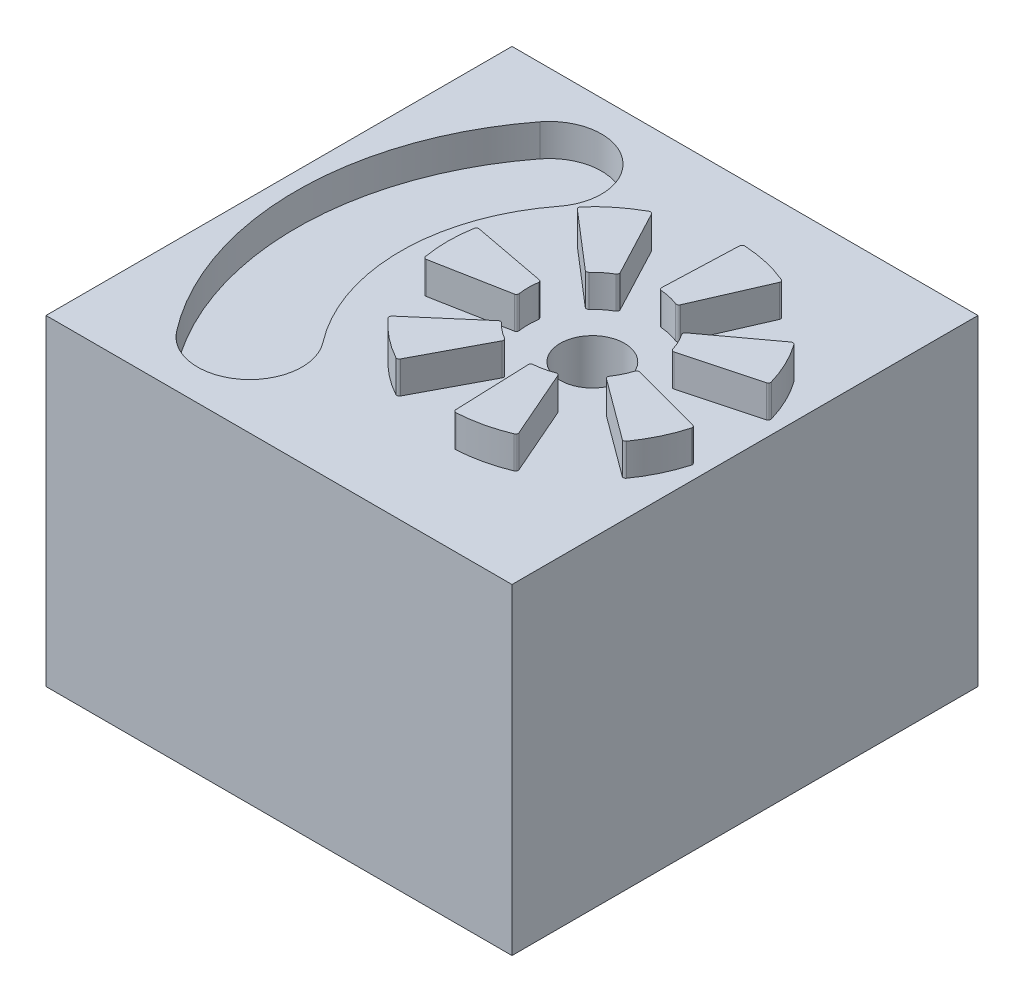
from build123d import *

# Parameters (mm, degrees)
SKETCH1_W           = 92.075
SKETCH1_H           = 92.075
BOSS_EXTRUDE1_DEPTH = 63.5
CUT_EXTRUDE1_DEPTH  = 6.35
BOSS_EXTRUDE2_DEPTH = 6.35
SKETCH5_R           = 6.35
CUT_EXTRUDE2_DEPTH  = 19.05


with BuildPart() as part:
    # Sketch1 → Boss-Extrude1 (new body)
    with BuildSketch(Plane(origin=(0, 0, 0), x_dir=(1, 0, 0), z_dir=(0, 1, 0))):
        Rectangle(SKETCH1_W, SKETCH1_H)
    extrude(amount=-BOSS_EXTRUDE1_DEPTH)

    # Sketch3 → Cut-Extrude1 (cut)
    with BuildSketch(Plane(origin=(0, 0, 0), x_dir=(1, 0, 0), z_dir=(0, 1, 0))):
        with BuildLine():
            ThreePointArc((-14.063201547, 23.287775446), (-15.921775446, 37.752798453), (-30.386798453, 35.894224554))
            ThreePointArc((-30.386798453, 35.894224554), (-42.633573767, 0), (-30.386798453, -35.894224554))
            ThreePointArc((-30.386798453, -35.894224554), (-15.921775446, -37.752798453), (-14.063201547, -23.287775446))
            ThreePointArc((-14.063201547, -23.287775446), (-22.008773767, 0), (-14.063201547, 23.287775446))
        make_face()
    extrude(amount=-CUT_EXTRUDE1_DEPTH, mode=Mode.SUBTRACT)

    # Sketch4 → Boss-Extrude2 (add)
    with BuildSketch(Plane(origin=(0, 0, 0), x_dir=(1, 0, 0), z_dir=(0, 1, 0))):
        with BuildLine():
            Line((42.981199166, 7.263084177), (28.623508469, 3.415952549))
            ThreePointArc((28.623508469, 3.415952549), (28.246537351, 3.461897832), (28.006758071, 3.756387374))
            ThreePointArc((28.006758071, 3.756387374), (27.317235926, 5.510466133), (26.375711245, 7.143182998))
            ThreePointArc((26.375711245, 7.143182998), (26.294960734, 7.5142592), (26.49406885, 7.837638468))
            Line((26.49406885, 7.837638468), (38.453531121, 16.664583926))
            ThreePointArc((38.453531121, 16.664583926), (38.835445953, 16.757478046), (39.169323269, 16.550079409))
            ThreePointArc((39.169323269, 16.550079409), (41.620030834, 12.3985488), (43.337949301, 7.894114306))
            ThreePointArc((43.337949301, 7.894114306), (43.291940716, 7.503766427), (42.981199166, 7.263084177))
        make_face()
        with BuildLine():
            Line((27.096930878, 25.720938792), (21.152865774, 12.096996853))
            ThreePointArc((21.152865774, 12.096996853), (20.881906657, 11.830915381), (20.502165527, 11.827059617))
            ThreePointArc((20.502165527, 11.827059617), (18.700861504, 12.381619715), (16.837321021, 12.663488392))
            ThreePointArc((16.837321021, 12.663488392), (16.496854843, 12.831717328), (16.368168631, 13.189009997))
            Line((16.368168631, 13.189009997), (16.923587539, 28.042804588))
            ThreePointArc((16.923587539, 28.042804588), (17.089079994, 28.399316164), (17.45939988, 28.531041026))
            ThreePointArc((17.45939988, 28.531041026), (22.233188385, 27.858644358), (26.826001728, 26.39329813))
            ThreePointArc((26.826001728, 26.39329813), (27.102502105, 26.113949248), (27.096930878, 25.720938792))
        make_face()
        with BuildLine():
            Line((2.762319753, 24.810401886), (9.707882502, 11.668755794))
            ThreePointArc((9.707882502, 11.668755794), (9.746973129, 11.291012341), (9.513222964, 10.991714741))
            ThreePointArc((9.513222964, 10.991714741), (7.956555733, 9.929161112), (6.57428344, 8.647928739))
            ThreePointArc((6.57428344, 8.647928739), (6.230479572, 8.486630588), (5.870902373, 8.608787991))
            Line((5.870902373, 8.608787991), (-5.395963847, 18.304221426))
            ThreePointArc((-5.395963847, 18.304221426), (-5.571512963, 18.65588997), (-5.443608935, 19.027546823))
            ThreePointArc((-5.443608935, 19.027546823), (-1.941499602, 22.340612501), (2.067726493, 25.017790136))
            ThreePointArc((2.067726493, 25.017790136), (2.458525409, 25.059795657), (2.762319753, 24.810401886))
        make_face()
        with BuildLine():
            Line((-11.698175696, 5.21712632), (2.906864493, 2.453703622))
            ThreePointArc((2.906864493, 2.453703622), (3.226568823, 2.248746714), (3.314828266, 1.879384474))
            ThreePointArc((3.314828266, 1.879384474), (3.175000001, -0.000158326), (3.314875129, -1.87969764))
            ThreePointArc((3.314875129, -1.87969764), (3.226624896, -2.24906208), (2.906925676, -2.454026959))
            Line((2.906925676, -2.454026959), (-11.698045607, -5.217813808))
            ThreePointArc((-11.698045607, -5.217813808), (-12.08244423, -5.135801882), (-12.293270401, -4.804078229))
            ThreePointArc((-12.293270401, -4.804078229), (-12.699999998, -0.000356234), (-12.293390173, 4.803375901))
            ThreePointArc((-12.293390173, 4.803375901), (-12.082572273, 5.13510481), (-11.698175696, 5.21712632))
        make_face()
        with BuildLine():
            Line((-5.395507456, -18.304751776), (5.871117022, -8.609037424))
            ThreePointArc((5.871117022, -8.609037424), (6.230691175, -8.486871055), (6.574499064, -8.648160634))
            ThreePointArc((6.574499064, -8.648160634), (7.956803301, -9.929358541), (9.513497025, -10.991873357))
            ThreePointArc((9.513497025, -10.991873357), (9.747254652, -11.291165129), (9.708173444, -11.668909556))
            Line((9.708173444, -11.668909556), (2.762938362, -24.81072882))
            ThreePointArc((2.762938362, -24.81072882), (2.459150236, -25.060130166), (2.068350273, -25.018134389))
            ThreePointArc((2.068350273, -25.018134389), (-1.940942572, -22.341056718), (-5.443134509, -19.02807836))
            ThreePointArc((-5.443134509, -19.02807836), (-5.571047804, -18.656424696), (-5.395507456, -18.304751776))
        make_face()
        with BuildLine():
            Line((16.924286738, -28.042778435), (16.368497476, -13.188997697))
            ThreePointArc((16.368497476, -13.188997697), (16.49717478, -12.831701819), (16.837636763, -12.663464394))
            ThreePointArc((16.837636763, -12.663464394), (18.701170218, -12.381549253), (20.502460413, -11.826944243))
            ThreePointArc((20.502460413, -11.826944243), (20.882201639, -11.830790538), (21.15316739, -12.096865255))
            Line((21.15316739, -12.096865255), (27.097572182, -25.720658985))
            ThreePointArc((27.097572182, -25.720658985), (27.103153208, -26.113669301), (26.826659795, -26.393025077))
            ThreePointArc((26.826659795, -26.393025077), (22.23388299, -27.858485819), (17.460111251, -28.531001513))
            ThreePointArc((17.460111251, -28.531001513), (17.089788082, -28.399285884), (16.924286738, -28.042778435))
        make_face()
        with BuildLine():
            Line((38.453946616, -16.664020964), (26.494264265, -7.837373698))
            ThreePointArc((26.494264265, -7.837373698), (26.295148086, -7.513999394), (26.375889345, -7.142921178))
            ThreePointArc((26.375889345, -7.142921178), (27.317373317, -5.510180839), (28.006851726, -3.756084888))
            ThreePointArc((28.006851726, -3.756084888), (28.246623663, -3.461589368), (28.623593636, -3.415634686))
            Line((28.623593636, -3.415634686), (42.98138025, -7.262408328))
            ThreePointArc((42.98138025, -7.262408328), (43.292127801, -7.503082831), (43.338146119, -7.893429562))
            ThreePointArc((43.338146119, -7.893429562), (41.620339963, -12.397906888), (39.169735909, -16.549498601))
            ThreePointArc((39.169735909, -16.549498601), (38.835863765, -16.756905562), (38.453946616, -16.664020964))
        make_face()
    extrude(amount=BOSS_EXTRUDE2_DEPTH)

    # Sketch5 → Cut-Extrude2 (cut)
    with BuildSketch(Plane(origin=(0, 0, 0), x_dir=(1, 0, 0), z_dir=(0, 1, 0))):
        with Locations((15.875, 0)):
            Circle(SKETCH5_R)
    extrude(amount=-CUT_EXTRUDE2_DEPTH, mode=Mode.SUBTRACT)


solid = part.part
